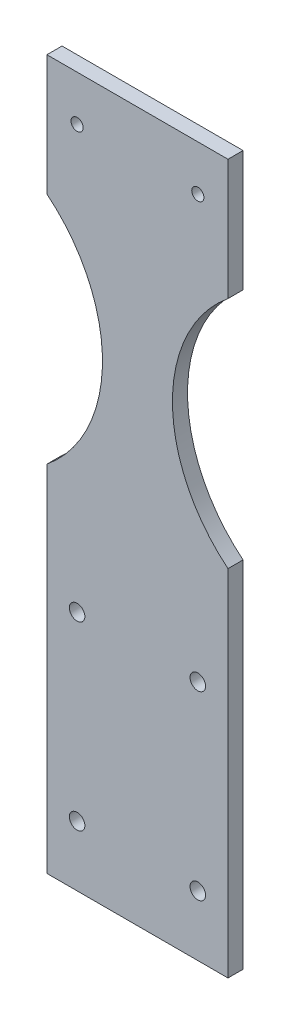
from build123d import *

# Parameters (mm, degrees)
SKETCH1_W                   = 76.2
SKETCH1_H                   = 298.45
BOSS_EXTRUDE1_DEPTH         = 6.35
F_1_4_20_TAPPED_HOLE1_D     = 5.1054
F_1_4_20_TAPPED_HOLE1_DEPTH = 6.35
CUT_EXTRUDE1_DEPTH          = 7.35
F_0_257_DIAMETER_HOLE1_D    = 6.5278


with BuildPart() as part:
    # Sketch1 → Boss-Extrude1 (new body)
    with BuildSketch(Plane.XY):
        Rectangle(SKETCH1_W, SKETCH1_H)
    extrude(amount=BOSS_EXTRUDE1_DEPTH)

    # 1/4-20 Tapped Hole1
    with Locations(Plane(origin=(0, 0, 0), x_dir=(-1, 0, 0), z_dir=(0, 0, -1))):
        with Locations((-25.4, 130.175), (25.4, 130.175), (25.4, -47.625), (25.4, -123.825), (-25.4, -123.825), (-25.4, -47.625)):
            Hole(F_1_4_20_TAPPED_HOLE1_D / 2, depth=F_1_4_20_TAPPED_HOLE1_DEPTH)

    # Sketch6 → Cut-Extrude1 (cut, through all)
    with BuildSketch(Plane(origin=(0, 0, 0), x_dir=(-1, 0, 0), z_dir=(0, 0, -1))):
        with BuildLine():
            Line((-38.1, 98.425), (-38.1, 0))
            ThreePointArc((-38.1, 0), (-14.729538295, 49.2125), (-38.1, 98.425))
        make_face()
        with BuildLine():
            Line((38.1, 98.425), (38.1, 0))
            ThreePointArc((38.1, 0), (14.729538295, 49.2125), (38.1, 98.425))
        make_face()
    extrude(amount=-CUT_EXTRUDE1_DEPTH, mode=Mode.SUBTRACT)

    # F (0.257) Diameter Hole1 (through all)
    with Locations(Plane(origin=(0, 0, 0), x_dir=(-1, 0, 0), z_dir=(0, 0, -1))):
        with Locations((-25.4, -47.625), (25.4, -47.625), (25.4, -123.825), (-25.4, -123.825)):
            Hole(F_0_257_DIAMETER_HOLE1_D / 2)


solid = part.part
